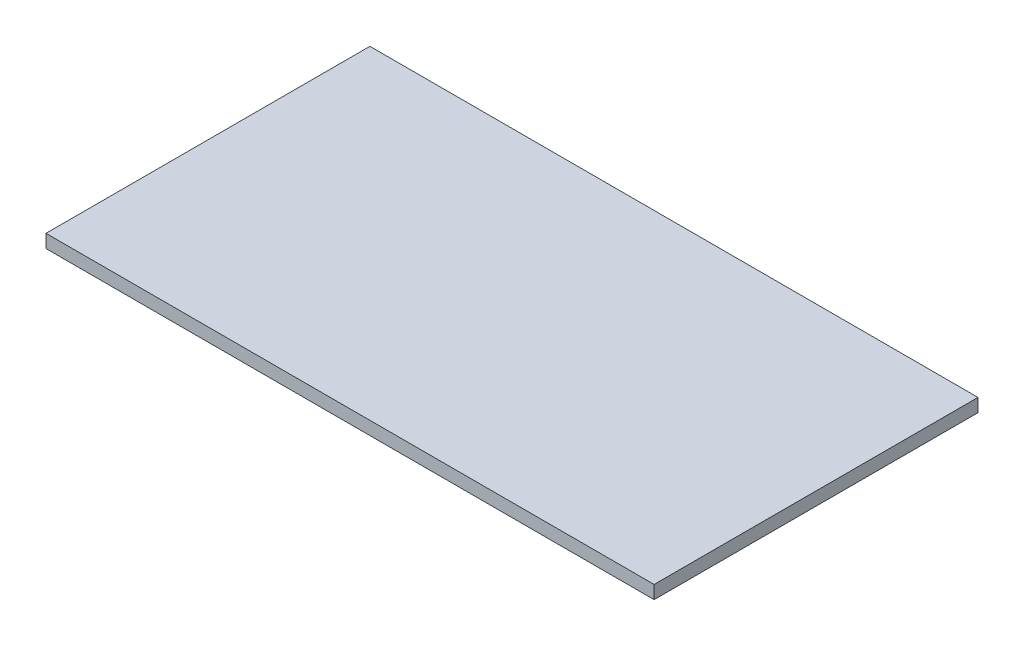
from build123d import *

# Parameters (mm, degrees)
SKETCH1_W           = 876.3
SKETCH1_H           = 466.725
BOSS_EXTRUDE1_DEPTH = 19.05


with BuildPart() as part:
    # Sketch1 → Boss-Extrude1 (new body)
    with BuildSketch(Plane(origin=(0, 0, 0), x_dir=(1, 0, 0), z_dir=(0, 1, 0))):
        Rectangle(SKETCH1_W, SKETCH1_H)
    extrude(amount=BOSS_EXTRUDE1_DEPTH)


solid = part.part
